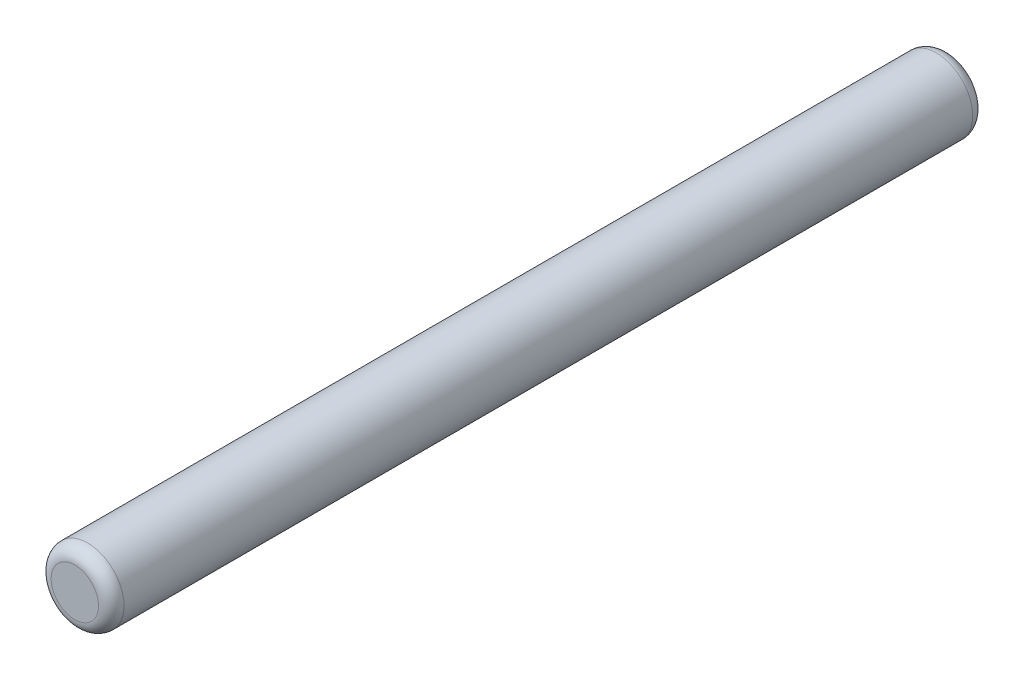
from build123d import *

# Parameters (mm, degrees)
SKETCH1_R           = 1
BOSS_EXTRUDE1_DEPTH = 12
FILLET1_R           = 0.35


with BuildPart() as part:
    # Sketch1 → Boss-Extrude1 (new body, symmetric)
    with BuildSketch(Plane.XY):
        Circle(SKETCH1_R)
    extrude(amount=BOSS_EXTRUDE1_DEPTH, both=True)

    # Fillet1
    fillet1_edges = [part.edges().sort_by_distance(p)[0] for p in [
        (-1, 0, -12),
        (-1, 0, 12),
    ]]
    fillet(fillet1_edges, radius=FILLET1_R)


solid = part.part
